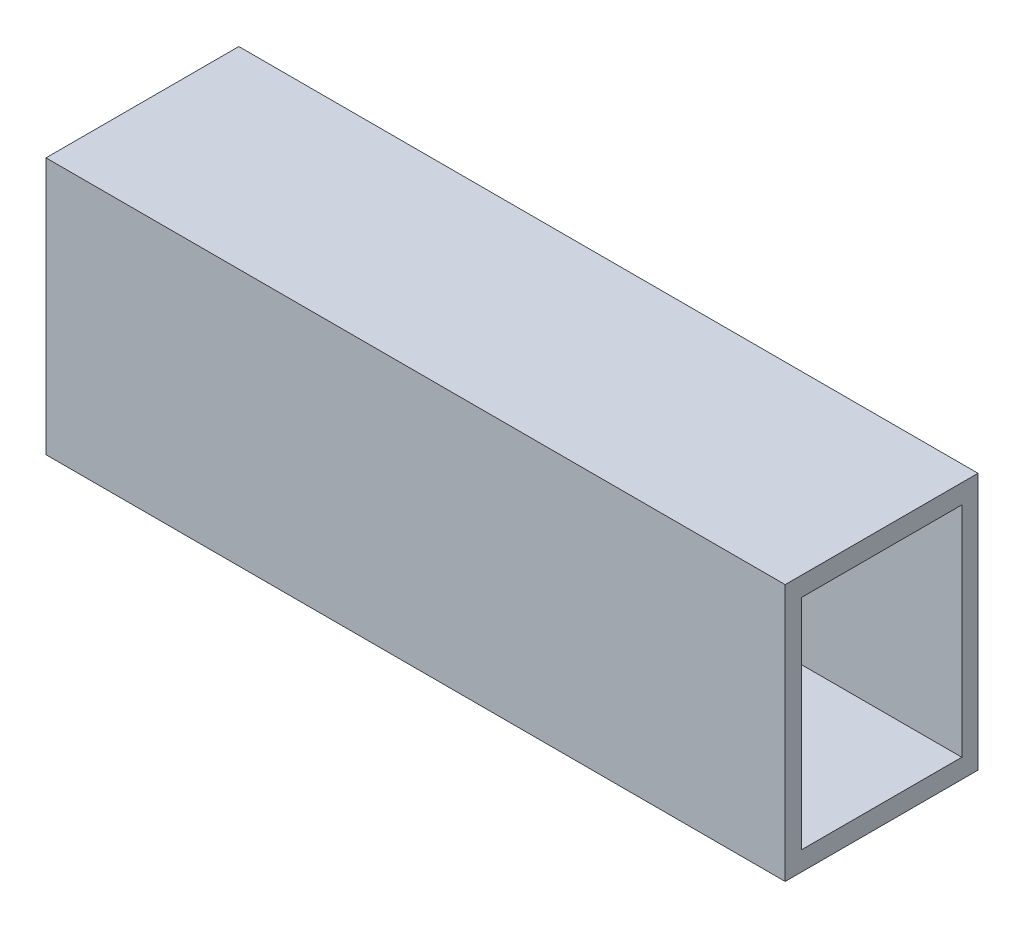
from build123d import *

# Parameters (mm, degrees)
CROQUIS1_W              = 30
CROQUIS1_H              = 40
CROQUIS1_W_2            = 24.961062678
CROQUIS1_H_2            = 34
SALIENTE_EXTRUIR1_DEPTH = 115


with BuildPart() as part:
    # Croquis1 → Saliente-Extruir1 (new body)
    with BuildSketch(Plane(origin=(0, 0, 0), x_dir=(0, 0, -1), z_dir=(1, 0, 0))):
        Rectangle(CROQUIS1_W, CROQUIS1_H)
        Rectangle(CROQUIS1_W_2, CROQUIS1_H_2, mode=Mode.SUBTRACT)
    extrude(amount=SALIENTE_EXTRUIR1_DEPTH)


solid = part.part
